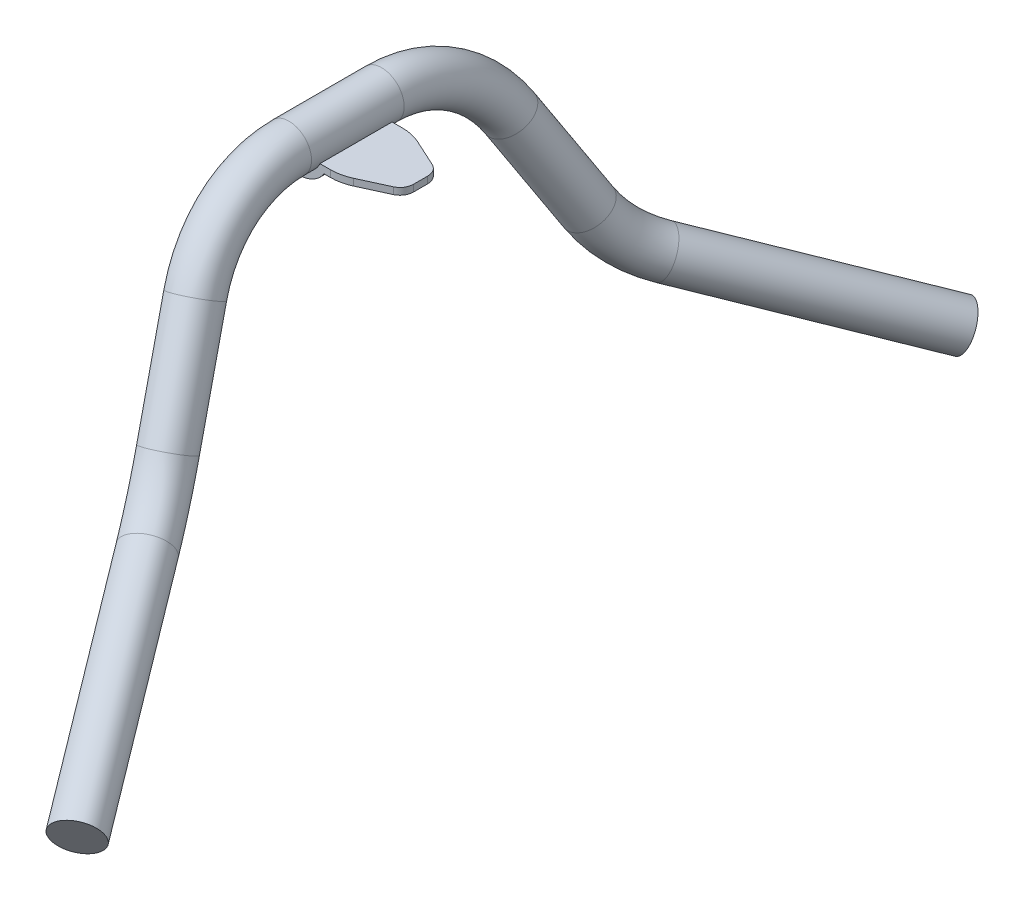
from build123d import *

# Parameters (mm, degrees)
BOSS_EXTRUDE1_DEPTH = 10.16
SKETCH2_OUTSIDE_W   = 88.516
SKETCH2_OUTSIDE_H   = 38.986
CUT_EXTRUDE1_DEPTH  = 41.64
SKETCH3_R           = 12.7


with BuildPart() as part:
    # Sketch1 → Boss-Extrude1 (new body, symmetric)
    with BuildSketch(Plane(origin=(0, 0, 0), x_dir=(1, 0, 0), z_dir=(0, 1, 0))):
        with BuildLine():
            Line((4.607085175, 20.32), (-28.448, 20.32))
            ThreePointArc((-28.448, 20.32), (-32.938128061, 18.460128061), (-34.798, 13.97))
            Line((-34.798, 13.97), (-34.798, -13.97))
            ThreePointArc((-34.798, -13.97), (-32.938128061, -18.460128061), (-28.448, -20.32))
            Line((-28.448, -20.32), (4.607085175, -20.32))
            ThreePointArc((4.607085175, -20.32), (10.031876423, -19.733940435), (15.206332963, -18.002806293))
            Line((15.206332963, -18.002806293), (30.611774336, -10.928879131))
            ThreePointArc((30.611774336, -10.928879131), (33.846603668, -8.117096905), (35.052, -4.004037244))
            Line((35.052, -4.004037244), (35.052, 4.004037244))
            ThreePointArc((35.052, 4.004037244), (33.846603668, 8.117096905), (30.611774336, 10.928879131))
            Line((30.611774336, 10.928879131), (15.206332963, 18.002806293))
            ThreePointArc((15.206332963, 18.002806293), (10.031876423, 19.733940435), (4.607085175, 20.32))
        make_face()
    extrude(amount=BOSS_EXTRUDE1_DEPTH, both=True)

    # Sketch2 outside → Cut-Extrude1 (cut, through all)
    with BuildSketch(Plane.XY.offset(20.32)):
        with Locations((0.127, 0)):
            Rectangle(SKETCH2_OUTSIDE_W, SKETCH2_OUTSIDE_H)
        with BuildLine():
            Line((-34.798, 10.16), (-24.638, 10.16))
            ThreePointArc((-24.638, 10.16), (-12.998257735, 2.54), (-1.35851547, 10.16))
            Line((-1.35851547, 10.16), (35.052, 10.16))
            Line((35.052, 10.16), (35.052, 6.35))
            Line((35.052, 6.35), (0.913895226, 6.35))
            ThreePointArc((0.913895226, 6.35), (-12.998257735, -1.27), (-26.910410695, 6.35))
            Line((-26.910410695, 6.35), (-34.798, 6.35))
            Line((-34.798, 6.35), (-34.798, 10.16))
        make_face(mode=Mode.SUBTRACT)
    extrude(amount=-CUT_EXTRUDE1_DEPTH, mode=Mode.SUBTRACT)

    # Sweep1: sweep along a curve in space
    with BuildLine() as sweep1_path:
        Line((-12.998257735, 15.24, 0), (-12.998257735, 15.24, 26.090581637))
        ThreePointArc((-12.998257735, 15.24, 26.090581637), (-10.369052155, 5.523370683, 62.566204639), (-3.225691511, -20.876005608, 88.716577691))
        Line((-3.225691511, -20.876005608, 88.716577691), (11.214051911, -74.240274777, 118.469971898))
        ThreePointArc((26.634638374, -101.71962206, 145.570889864), (17.598298945, -90.292217187, 130.430402583), (11.214051911, -74.240274777, 118.469971898))
        Line((26.634638374, -101.71962206, 145.570889864), (91.141742265, -157.48, 249.564780828))
    # Sketch3 → Sweep1 (sweep)
    with BuildSketch(Plane.XY):
        with Locations((-12.998257735, 15.24)):
            Circle(SKETCH3_R)
    sweep(path=sweep1_path.line)

    # Mirror1: part across plane


with BuildPart() as part_1:
    add(part.part)
    add(part.part.mirror(Plane.XY))


solid = part_1.part
